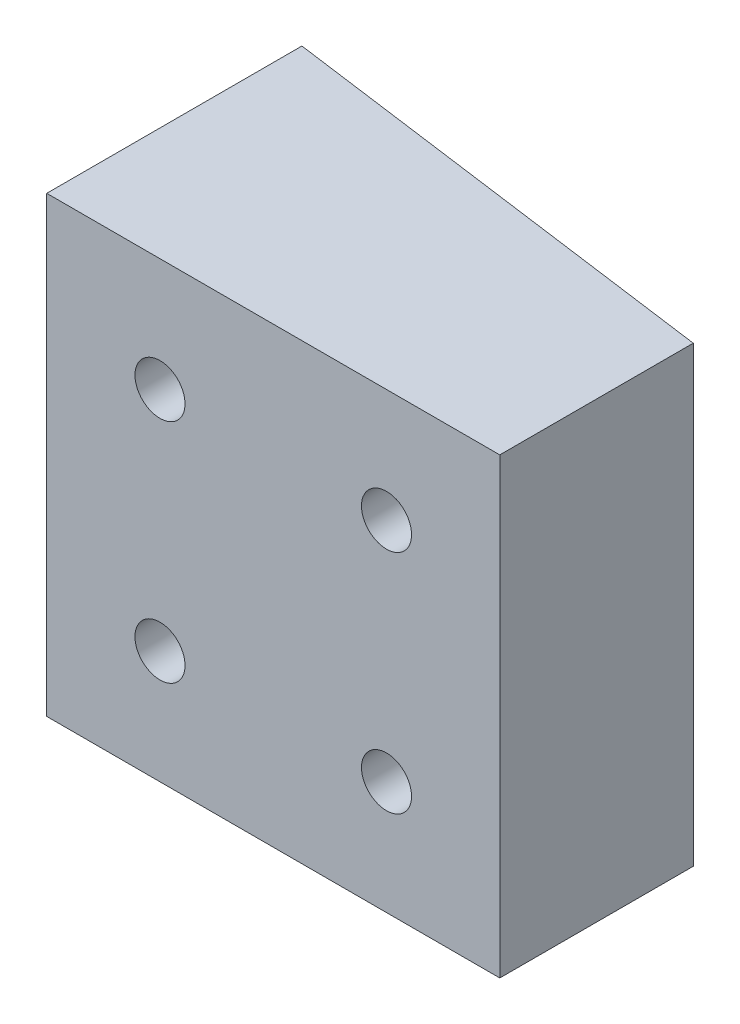
from build123d import *

# Parameters (mm, degrees)
BOSS_EXTRUDE1_DEPTH                                = 50.8
CSK_FOR_10_FLAT_HEAD_MACHINE_SCREW_100_D           = 5.6134
CSK_FOR_10_FLAT_HEAD_MACHINE_SCREW_100_CSINK_D     = 17.78
CSK_FOR_10_FLAT_HEAD_MACHINE_SCREW_100_CSINK_ANGLE = 90
CSK_FOR_10_FLAT_HEAD_MACHINE_SCREW_2_D             = 5.6134
CSK_FOR_10_FLAT_HEAD_MACHINE_SCREW_2_CSINK_D       = 17.78
CSK_FOR_10_FLAT_HEAD_MACHINE_SCREW_2_CSINK_ANGLE   = 90


with BuildPart() as part:
    # Sketch1 → Boss-Extrude1 (new body)
    with BuildSketch(Plane(origin=(0, 0, 0), x_dir=(1, 0, 0), z_dir=(0, 1, 0))):
        Polygon((50.8, 0), (0, 0), (0, 28.609796644), (50.8, 21.69437447), align=None)
    extrude(amount=BOSS_EXTRUDE1_DEPTH)

    # CSK for _10 Flat Head Machine Screw _100 (through all)
    with Locations(Plane(origin=(320.741972913, -316.395089466, -35.56), x_dir=(1, 0, 0), z_dir=(0, 0, -1))):
        with Locations((-308.041854919, -227.495089466), (-308.041854919, -252.895089466), (-308.041972913, -329.095089466), (-308.041972913, -354.495089466)):
            CounterSinkHole(CSK_FOR_10_FLAT_HEAD_MACHINE_SCREW_100_D / 2, CSK_FOR_10_FLAT_HEAD_MACHINE_SCREW_100_CSINK_D / 2, counter_sink_angle=CSK_FOR_10_FLAT_HEAD_MACHINE_SCREW_100_CSINK_ANGLE)

    # CSK for _10 Flat Head Machine Screw  2 (through all)
    with Locations(Plane(origin=(320.741972913, -316.395089466, -33.02), x_dir=(1, 0, 0), z_dir=(0, 0, -1))):
        with Locations((-282.641854919, -227.495089466), (-282.641854919, -252.895089466), (-282.641972913, -329.095089466), (-282.641972913, -354.495089466)):
            CounterSinkHole(CSK_FOR_10_FLAT_HEAD_MACHINE_SCREW_2_D / 2, CSK_FOR_10_FLAT_HEAD_MACHINE_SCREW_2_CSINK_D / 2, counter_sink_angle=CSK_FOR_10_FLAT_HEAD_MACHINE_SCREW_2_CSINK_ANGLE)


solid = part.part
